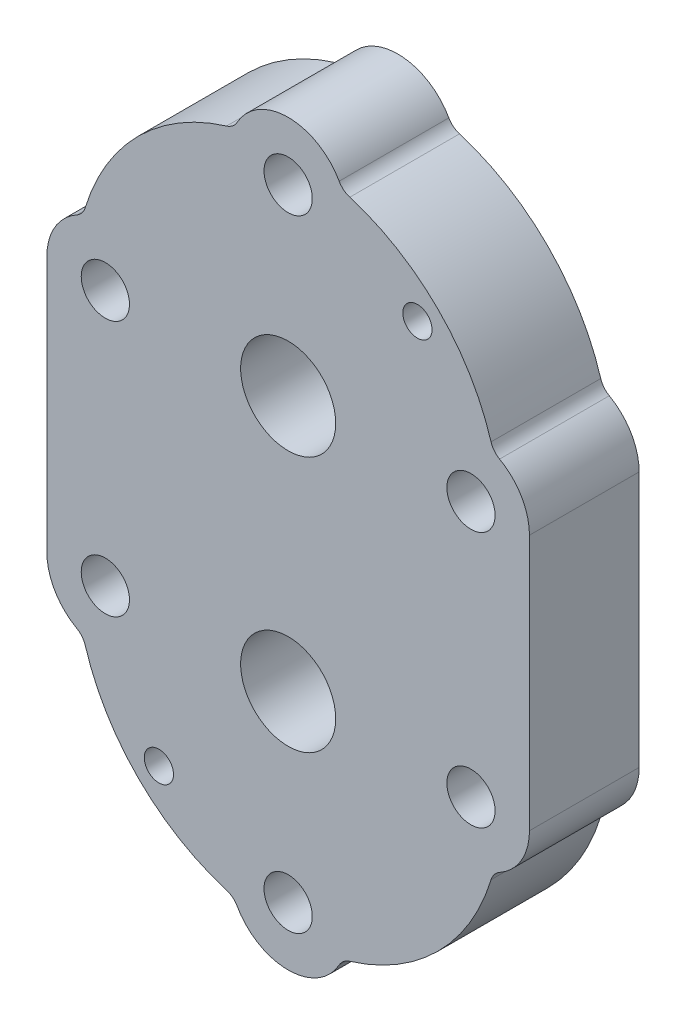
from build123d import *

# Parameters (mm, degrees)
SKETCH_3_R                  = 2
EXTRUDE_4_DEPTH             = 15
EXTRUDE_5_DEPTH             = 7
HOLE_WIZARD_13_0_13_2_D     = 13
HOLE_WIZARD_13_0_13_2_DEPTH = 15
HOLE_WIZARD_13_0_13_2_TIP   = 3.905594024
HOLE_WIZARD_2_D             = 6.6
HOLE_WIZARD_2_DEPTH         = 15
HOLE_WIZARD_2_CBORE_D       = 11
HOLE_WIZARD_2_CBORE_DEPTH   = 6.8
HOLE_WIZARD_2_TIP           = 1.982840043
FILLET_1_R                  = 1


with BuildPart() as part:
    # 草图3 → 凸台-拉伸4 (new body)
    with BuildSketch(Plane.XY):
        with BuildLine():
            ThreePointArc((-28.916190476, 24.475919449), (-31.903967114, 21.541687531), (-33, 17.5))
            Line((-33, 17.5), (-33, -17.5))
            ThreePointArc((-33, -17.5), (-31.903967114, -21.541687531), (-28.916190476, -24.475919449))
            ThreePointArc((-28.916190476, -24.475919449), (-28.191496301, -25.08958226), (-27.747936508, -25.929236))
            ThreePointArc((-27.747936508, -25.929236), (-20.506096654, -38.006096654), (-8.429236, -45.247936508))
            ThreePointArc((-8.429236, -45.247936508), (-7.58958226, -45.691496301), (-6.975919449, -46.416190476))
            ThreePointArc((-6.975919449, -46.416190476), (0, -50.5), (6.975919449, -46.416190476))
            ThreePointArc((6.975919449, -46.416190476), (7.58958226, -45.691496301), (8.429236, -45.247936508))
            ThreePointArc((8.429236, -45.247936508), (20.506096654, -38.006096654), (27.747936508, -25.929236))
            ThreePointArc((27.747936508, -25.929236), (28.191496301, -25.08958226), (28.916190476, -24.475919449))
            ThreePointArc((28.916190476, -24.475919449), (31.903967114, -21.541687531), (33, -17.5))
            Line((33, -17.5), (33, 17.5))
            ThreePointArc((33, 17.5), (31.903967114, 21.541687531), (28.916190476, 24.475919449))
            ThreePointArc((28.916190476, 24.475919449), (28.191496301, 25.08958226), (27.747936508, 25.929236))
            ThreePointArc((27.747936508, 25.929236), (20.506096654, 38.006096654), (8.429236, 45.247936508))
            ThreePointArc((8.429236, 45.247936508), (7.58958226, 45.691496301), (6.975919449, 46.416190476))
            ThreePointArc((6.975919449, 46.416190476), (0, 50.5), (-6.975919449, 46.416190476))
            ThreePointArc((-6.975919449, 46.416190476), (-7.58958226, 45.691496301), (-8.429236, 45.247936508))
            ThreePointArc((-8.429236, 45.247936508), (-20.506096654, 38.006096654), (-27.747936508, 25.929236))
            ThreePointArc((-27.747936508, 25.929236), (-28.191496301, 25.08958226), (-28.916190476, 24.475919449))
        make_face()
        with Locations((-17.67766953, -35.17766953)):
            Circle(SKETCH_3_R, mode=Mode.SUBTRACT)
        with Locations((17.67766953, 35.17766953)):
            Circle(SKETCH_3_R, mode=Mode.SUBTRACT)
    extrude(amount=EXTRUDE_4_DEPTH)

    # 草图3<6> → 凸台-拉伸5 (add)
    with BuildSketch(Plane.XY):
        with BuildLine():
            Line((-14, 17.5), (-14, -17.5))
            ThreePointArc((-14, -17.5), (0, -31.5), (14, -17.5))
            Line((14, -17.5), (14, 17.5))
            ThreePointArc((14, 17.5), (0, 31.5), (-14, 17.5))
        make_face()
    extrude(amount=-EXTRUDE_5_DEPTH)

    # Ø13.0 (13) 直径孔2
    with Locations(Plane(origin=(0, 17.5, 15), x_dir=(1, 0, 0), z_dir=(0, 0, 1))):
        with Locations((0, 0), (0, -35)):
            Hole(HOLE_WIZARD_13_0_13_2_D / 2, depth=HOLE_WIZARD_13_0_13_2_DEPTH)
            with Locations((0, 0, -(HOLE_WIZARD_13_0_13_2_DEPTH + HOLE_WIZARD_13_0_13_2_TIP / 2))):  # 118° drill point
                Cone(0, HOLE_WIZARD_13_0_13_2_D / 2, HOLE_WIZARD_13_0_13_2_TIP, mode=Mode.SUBTRACT)

    # 打孔尺寸(%根据)开槽圆柱头螺钉的类型2
    with Locations(Plane(origin=(0, 0, 0), x_dir=(-1, 0, 0), z_dir=(0, 0, -1))):
        with Locations((0, 42.5), (-25, 17.5), (25, 17.5), (-25, -17.5), (25, -17.5), (0, -42.5)):
            CounterBoreHole(HOLE_WIZARD_2_D / 2, HOLE_WIZARD_2_CBORE_D / 2, HOLE_WIZARD_2_CBORE_DEPTH, depth=HOLE_WIZARD_2_DEPTH)
            with Locations((0, 0, -(HOLE_WIZARD_2_DEPTH + HOLE_WIZARD_2_TIP / 2))):  # 118° drill point
                Cone(0, HOLE_WIZARD_2_D / 2, HOLE_WIZARD_2_TIP, mode=Mode.SUBTRACT)

    # 圆角1
    fillet_1_edges = [part.edges().sort_by_distance(p)[0] for p in [
        (0, -31.5, -7),
        (-14, 0, -7),
        (0, 31.5, -7),
        (14, 0, -7),
        (0, 31.5, 0),
        (-14, 0, 0),
        (0, -31.5, 0),
        (14, 0, 0),
    ]]
    fillet(fillet_1_edges, radius=FILLET_1_R)


solid = part.part
